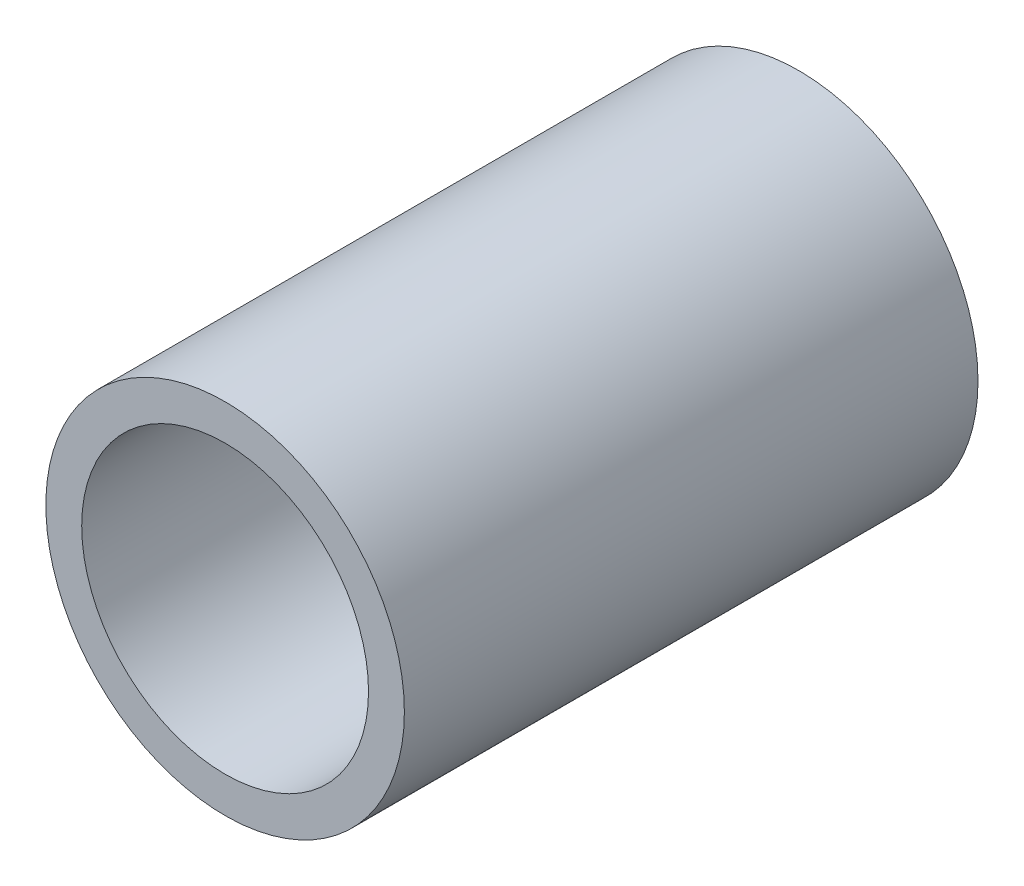
from build123d import *

# Parameters (mm, degrees)
SKETCH1_R           = 7.5
SKETCH1_R_2         = 6
BOSS_EXTRUDE1_DEPTH = 12


with BuildPart() as part:
    # Sketch1 → Boss-Extrude1 (new body, symmetric)
    with BuildSketch(Plane.XY):
        Circle(SKETCH1_R)
        Circle(SKETCH1_R_2, mode=Mode.SUBTRACT)
    extrude(amount=BOSS_EXTRUDE1_DEPTH, both=True)


solid = part.part
